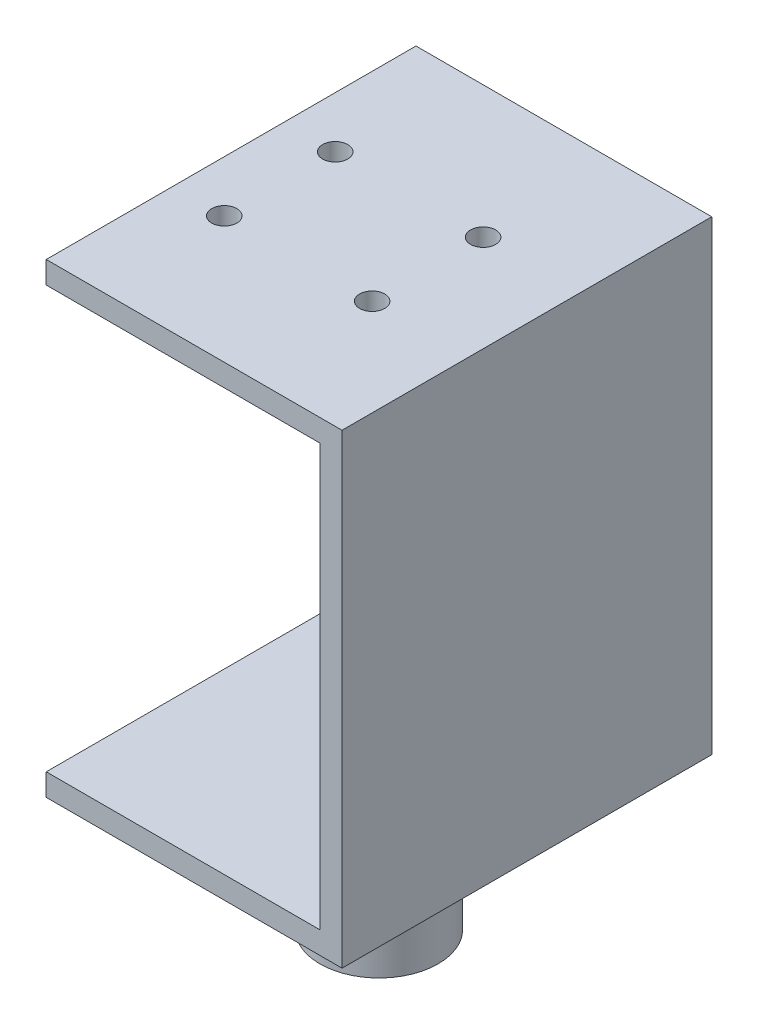
from build123d import *

# Parameters (mm, degrees)
BOSS_EXTRUDE1_DEPTH       = 25
SKETCH3_R                 = 8
BOSS_EXTRUDE2_DEPTH       = 18
M3_CLEARANCE_HOLE1_REACH  = 89.098
M3_CLEARANCE_HOLE1_BORE_R = 1.7


with BuildPart() as part:
    # Sketch2 → Boss-Extrude1 (new, symmetric)
    with BuildSketch(Plane.XY):
        Polygon((-20, 20), (20, 20), (20, -40), (20, -43), (-20, -43), (-20, -40), (17, -40), (17, 17), (-20, 17), align=None)
    extrude(amount=BOSS_EXTRUDE1_DEPTH, both=True)

    # Sketch3 → Boss-Extrude2 (add)
    with BuildSketch(Plane.XZ.offset(43)):
        Circle(SKETCH3_R)
    extrude(amount=BOSS_EXTRUDE2_DEPTH)

    # M3 Clearance Hole1 bore → M3 Clearance Hole1 (cut, up to next)
    with BuildSketch(Plane(origin=(0, 20, 0), x_dir=(1, 0, 0), z_dir=(0, 1, 0)), mode=Mode.PRIVATE) as m3_clearance_hole1_sk1:
        with Locations((-13.072595628, -7.85)):
            Circle(M3_CLEARANCE_HOLE1_BORE_R)
    m3_clearance_hole1_tool1 = extrude(m3_clearance_hole1_sk1.sketch, amount=-M3_CLEARANCE_HOLE1_REACH, mode=Mode.PRIVATE) & part.part
    # M3 Clearance Hole1 bore → M3 Clearance Hole1 (cut, up to next)
    with BuildSketch(Plane(origin=(0, 20, 0), x_dir=(1, 0, 0), z_dir=(0, 1, 0)), mode=Mode.PRIVATE) as m3_clearance_hole1_sk2:
        with Locations((-13.072595628, 7.15)):
            Circle(M3_CLEARANCE_HOLE1_BORE_R)
    m3_clearance_hole1_tool2 = extrude(m3_clearance_hole1_sk2.sketch, amount=-M3_CLEARANCE_HOLE1_REACH, mode=Mode.PRIVATE) & part.part
    # M3 Clearance Hole1 bore → M3 Clearance Hole1 (cut, up to next)
    with BuildSketch(Plane(origin=(0, 20, 0), x_dir=(1, 0, 0), z_dir=(0, 1, 0)), mode=Mode.PRIVATE) as m3_clearance_hole1_sk3:
        with Locations((6.927404372, -7.85)):
            Circle(M3_CLEARANCE_HOLE1_BORE_R)
    m3_clearance_hole1_tool3 = extrude(m3_clearance_hole1_sk3.sketch, amount=-M3_CLEARANCE_HOLE1_REACH, mode=Mode.PRIVATE) & part.part
    # M3 Clearance Hole1 bore → M3 Clearance Hole1 (cut, up to next)
    with BuildSketch(Plane(origin=(0, 20, 0), x_dir=(1, 0, 0), z_dir=(0, 1, 0)), mode=Mode.PRIVATE) as m3_clearance_hole1_sk4:
        with Locations((6.927404372, 7.15)):
            Circle(M3_CLEARANCE_HOLE1_BORE_R)
    m3_clearance_hole1_tool4 = extrude(m3_clearance_hole1_sk4.sketch, amount=-M3_CLEARANCE_HOLE1_REACH, mode=Mode.PRIVATE) & part.part
    add(m3_clearance_hole1_tool1.solids().sort_by_distance((-13.072596, 20, 7.85))[0], mode=Mode.SUBTRACT)
    add(m3_clearance_hole1_tool2.solids().sort_by_distance((-13.072596, 20, -7.15))[0], mode=Mode.SUBTRACT)
    add(m3_clearance_hole1_tool3.solids().sort_by_distance((6.927404, 20, 7.85))[0], mode=Mode.SUBTRACT)
    add(m3_clearance_hole1_tool4.solids().sort_by_distance((6.927404, 20, -7.15))[0], mode=Mode.SUBTRACT)


solid = part.part
